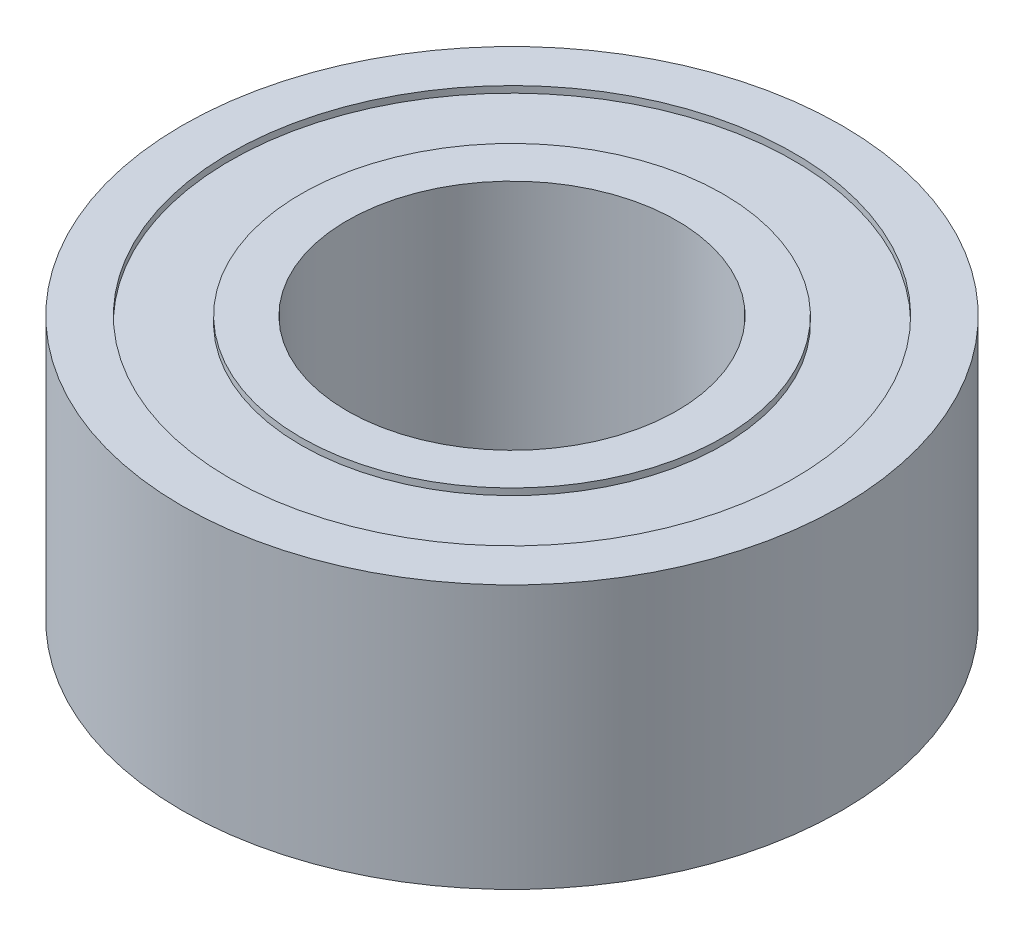
from build123d import *

# Parameters (mm, degrees)
SKETCH1_R           = 5
SKETCH1_R_2         = 2.5
BOSS_EXTRUDE1_DEPTH = 4
SKETCH2_R           = 4.275
SKETCH2_R_2         = 3.2
CUT_EXTRUDE1_DEPTH  = 0.1
SKETCH3_R           = 4.275
SKETCH3_R_2         = 3.2
CUT_EXTRUDE2_DEPTH  = 0.1


with BuildPart() as part:
    # Sketch1 → Boss-Extrude1 (new body)
    with BuildSketch(Plane(origin=(0, 0, 0), x_dir=(1, 0, 0), z_dir=(0, 1, 0))):
        Circle(SKETCH1_R)
        Circle(SKETCH1_R_2, mode=Mode.SUBTRACT)
    extrude(amount=BOSS_EXTRUDE1_DEPTH)

    # Sketch2 → Cut-Extrude1 (cut)
    with BuildSketch(Plane(origin=(0, 4, 0), x_dir=(1, 0, 0), z_dir=(0, 1, 0))):
        Circle(SKETCH2_R)
        Circle(SKETCH2_R_2, mode=Mode.SUBTRACT)
    extrude(amount=-CUT_EXTRUDE1_DEPTH, mode=Mode.SUBTRACT)

    # Sketch3 → Cut-Extrude2 (cut)
    with BuildSketch(Plane.XZ):
        Circle(SKETCH3_R)
        Circle(SKETCH3_R_2, mode=Mode.SUBTRACT)
    extrude(amount=-CUT_EXTRUDE2_DEPTH, mode=Mode.SUBTRACT)


solid = part.part
